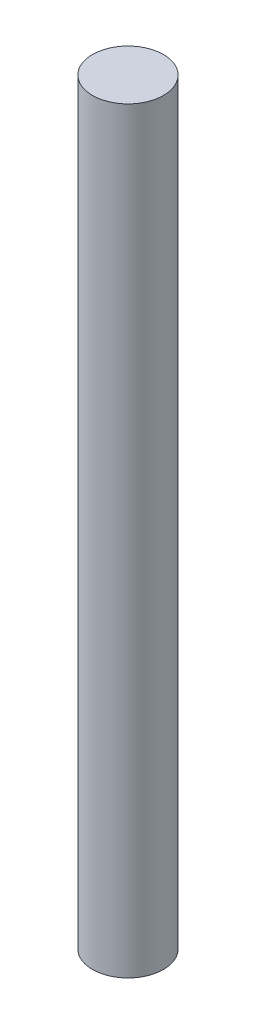
from build123d import *

# Parameters (mm, degrees)
SKETCH1_R           = 2.38125
BOSS_EXTRUDE1_DEPTH = 50.8


with BuildPart() as part:
    # Sketch1 → Boss-Extrude1 (new body)
    with BuildSketch(Plane(origin=(0, 0, 0), x_dir=(1, 0, 0), z_dir=(0, 1, 0))):
        Circle(SKETCH1_R)
    extrude(amount=BOSS_EXTRUDE1_DEPTH)


solid = part.part
